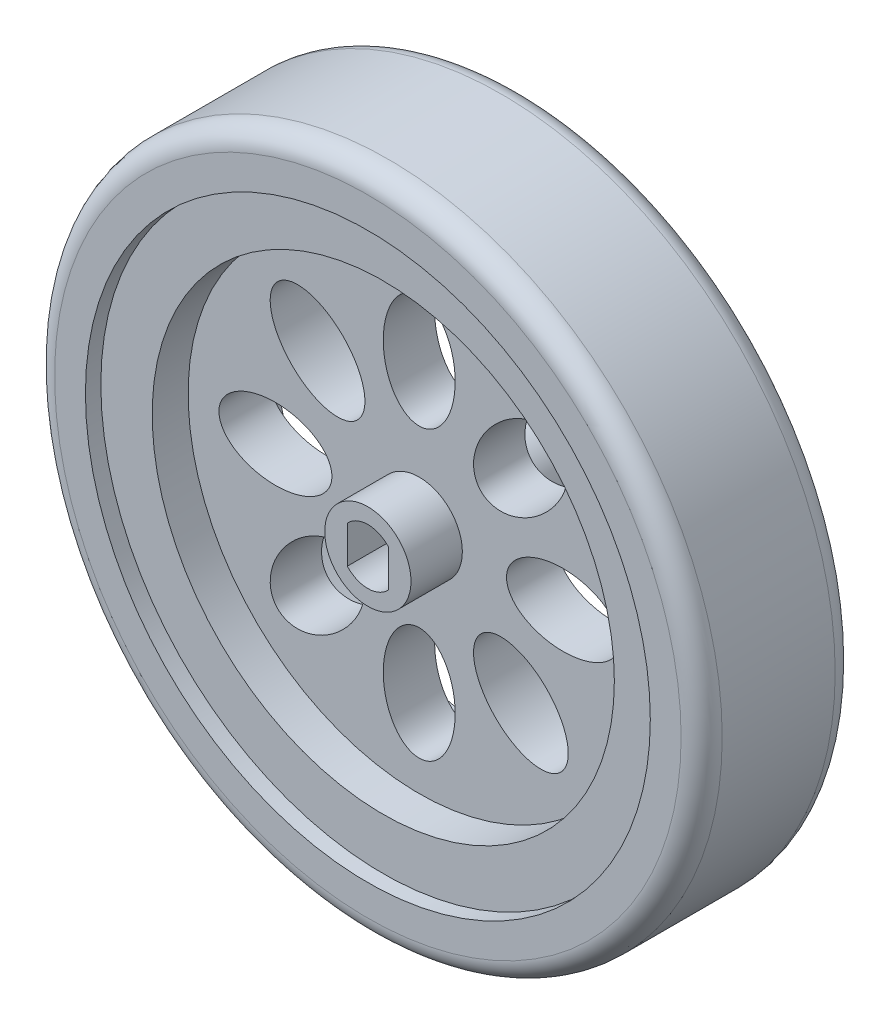
from build123d import *

# Parameters (mm, degrees)
SKETCH1_R           = 32.5
SKETCH1_R_2         = 27.5
BOSS_EXTRUDE1_DEPTH = 7.5
FILLET1_R           = 2
SKETCH3_R           = 4.2
BOSS_EXTRUDE2_DEPTH = 18.85
SKETCH4_R           = 27.5
SKETCH4_R_2         = 22.5
BOSS_EXTRUDE3_DEPTH = 6
SKETCH5_R           = 22.5
SKETCH5_R_2         = 4.2
BOSS_EXTRUDE4_DEPTH = 2.5
CUT_EXTRUDE1_START  = -12.35
SKETCH7_RX          = 5.5
SKETCH7_RY          = 3.5
CUT_EXTRUDE1_DEPTH  = 20.85
CIRPATTERN1_COUNT   = 8


with BuildPart() as part:
    # Sketch1 → Boss-Extrude1 (new body, symmetric)
    with BuildSketch(Plane.XY):
        Circle(SKETCH1_R)
        Circle(SKETCH1_R_2, mode=Mode.SUBTRACT)
    extrude(amount=BOSS_EXTRUDE1_DEPTH, both=True)

    # Fillet1
    fillet1_edges = [part.edges().sort_by_distance(p)[0] for p in [
        (-32.5, 0, -7.5),
        (-32.5, 0, 7.5),
    ]]
    fillet(fillet1_edges, radius=FILLET1_R)

    # Sketch4 → Boss-Extrude3 (add, symmetric)
    with BuildSketch(Plane.XY):
        Circle(SKETCH4_R)
        Circle(SKETCH4_R_2, mode=Mode.SUBTRACT)
    extrude(amount=BOSS_EXTRUDE3_DEPTH, both=True)



with BuildPart() as body_2:
    # Sketch3 → Boss-Extrude2 (new body)
    with BuildSketch(Plane.XY.offset(7.5)):
        Circle(SKETCH3_R)
        with BuildLine():
            Line((-2, 1.813835715), (-2, -1.813835715))
            ThreePointArc((-2, -1.813835715), (0, -2.7), (2, -1.813835715))
            Line((2, -1.813835715), (2, 1.813835715))
            ThreePointArc((2, 1.813835715), (0, 2.7), (-2, 1.813835715))
        make_face(mode=Mode.SUBTRACT)
    extrude(amount=-BOSS_EXTRUDE2_DEPTH)


with BuildPart() as part_1:
    add(part.part)

    add(body_2.part)  # Boss-Extrude4 merges body 2
    # Sketch5 → Boss-Extrude4 (add, symmetric)
    with BuildSketch(Plane.XY):
        Circle(SKETCH5_R)
        Circle(SKETCH5_R_2, mode=Mode.SUBTRACT)
    extrude(amount=BOSS_EXTRUDE4_DEPTH, both=True)

    # Sketch7 → Cut-Extrude1 (cut)
    with BuildSketch(Plane.XY.offset(CUT_EXTRUDE1_START)):
        with Locations(Location((0, 14), (0, 0, 90))):
            Ellipse(SKETCH7_RX, SKETCH7_RY)
    cut_extrude1 = extrude(amount=CUT_EXTRUDE1_DEPTH, mode=Mode.SUBTRACT)

    # CirPattern1: Cut-Extrude1 ×8 about axis
    cirpattern1_axis = Axis((0, 0, 6), (0, 0, -1))
    for i in range(1, CIRPATTERN1_COUNT):
        add(cut_extrude1.rotate(cirpattern1_axis, i * 360 / CIRPATTERN1_COUNT), mode=Mode.SUBTRACT)


solid = part_1.part
